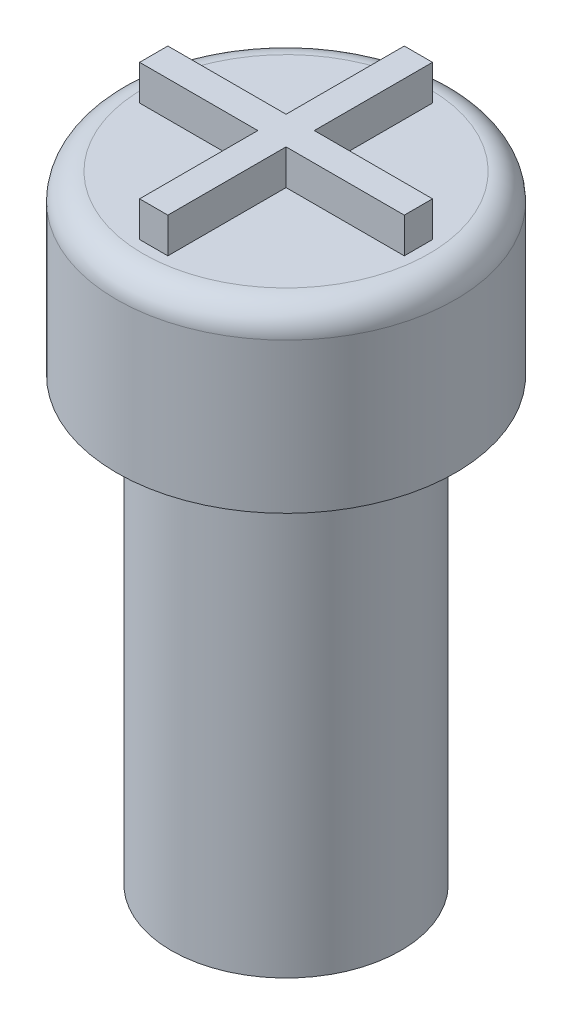
from build123d import *

# Parameters (mm, degrees)
SKETCH1_R           = 3.25
BOSS_EXTRUDE1_DEPTH = 12.5
SKETCH2_R           = 1.75
CUT_EXTRUDE1_DEPTH  = 2.5
SKETCH6_R           = 4.8
BOSS_EXTRUDE2_DEPTH = 5
BOSS_EXTRUDE3_DEPTH = 1
FILLET1_R           = 0.75


with BuildPart() as part:
    # Sketch1 → Boss-Extrude1 (new body)
    with BuildSketch(Plane(origin=(0, 0, 0), x_dir=(1, 0, 0), z_dir=(0, 1, 0))):
        Circle(SKETCH1_R)
    extrude(amount=BOSS_EXTRUDE1_DEPTH)

    # Sketch2 → Cut-Extrude1 (cut)
    with BuildSketch(Plane.XZ):
        Circle(SKETCH2_R)
    extrude(amount=-CUT_EXTRUDE1_DEPTH, mode=Mode.SUBTRACT)

    # Sketch6 → Boss-Extrude2 (add)
    with BuildSketch(Plane(origin=(0, 12.5, 0), x_dir=(1, 0, 0), z_dir=(0, 1, 0))):
        Circle(SKETCH6_R)
    extrude(amount=BOSS_EXTRUDE2_DEPTH)

    # Sketch8 → Boss-Extrude3 (add)
    with BuildSketch(Plane(origin=(0, 17.5, 0), x_dir=(1, 0, 0), z_dir=(0, 1, 0))):
        Polygon((0.4, 3.75), (-0.4, 3.75), (-0.4, 0.4), (-3.75, 0.4), (-3.75, -0.4), (-0.4, -0.4), (-0.4, -3.75), (0.4, -3.75), (0.4, -0.4), (3.75, -0.4), (3.75, 0.4), (0.4, 0.4), align=None)
    extrude(amount=BOSS_EXTRUDE3_DEPTH)

    # Fillet1
    fillet1_edges = [part.edges().sort_by_distance(p)[0] for p in [
        (-4.8, 17.5, 0),
    ]]
    fillet(fillet1_edges, radius=FILLET1_R)


solid = part.part
